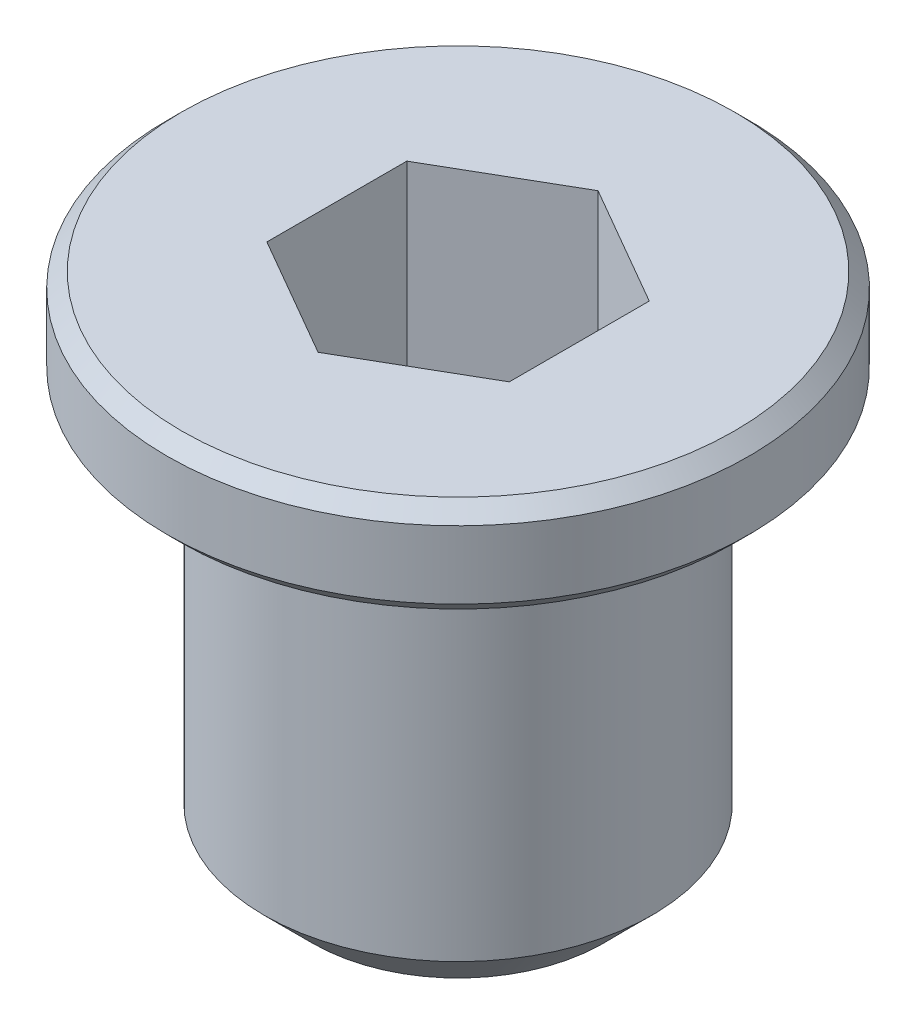
from build123d import *

# Parameters (mm, degrees)
ESQUISSE2_R             = 4
EXTRUSION1_DEPTH        = 8.5
ESQUISSE3_R             = 6
EXTRUSION2_DEPTH        = 2
ESQUISSE4_R             = 2
ENL_V_MAT_EXTRU_1_DEPTH = 11.5
ENL_V_MAT_EXTRU_2_DEPTH = 5.5
CHANFREIN1_SIZE         = 0.3
CHANFREIN2_SIZE         = 1


with BuildPart() as part:
    # Esquisse2 → Extrusion1 (new body)
    with BuildSketch(Plane(origin=(0, 0, 0), x_dir=(1, 0, 0), z_dir=(0, 1, 0))):
        with Locations(Location((0, 0, 0), (0, 0, 270))):  # turned: the seam where the file's is
            Circle(ESQUISSE2_R)
    extrude(amount=-EXTRUSION1_DEPTH)

    # Esquisse3 → Extrusion2 (add)
    with BuildSketch(Plane(origin=(0, 0, 0), x_dir=(-1, 0, 0), z_dir=(0, 1, 0))):
        with Locations(Location((0, 0, 0), (0, 0, 90))):  # turned: the seam where the file's is
            Circle(ESQUISSE3_R)
    extrude(amount=EXTRUSION2_DEPTH)

    # Esquisse4 → Enlèv. mat.-Extru.1 (cut, through all)
    with BuildSketch(Plane(origin=(0, 2, 0), x_dir=(-1, 0, 0), z_dir=(0, 1, 0))):
        with Locations(Location((0, 0, 0), (0, 0, 90))):  # turned: the seam where the file's is
            Circle(ESQUISSE4_R)
    extrude(amount=-ENL_V_MAT_EXTRU_1_DEPTH, mode=Mode.SUBTRACT)

    # Esquisse5 → Enlèv. mat.-Extru.2 (cut)
    with BuildSketch(Plane(origin=(0, 2, 0), x_dir=(-1, 0, 0), z_dir=(0, 1, 0))):
        Polygon((0, -2.886751346), (2.5, -1.443375673), (2.5, 1.443375673), (0, 2.886751346), (-2.5, 1.443375673), (-2.5, -1.443375673), align=None)
    extrude(amount=-ENL_V_MAT_EXTRU_2_DEPTH, mode=Mode.SUBTRACT)

    # Chanfrein1
    chanfrein1_edges = [part.edges().sort_by_distance(p)[0] for p in [
        (0, 0, -6),
        (0, 2, -6),
    ]]
    chamfer(chanfrein1_edges, length=CHANFREIN1_SIZE)

    # Chanfrein2
    chanfrein2_edges = [part.edges().sort_by_distance(p)[0] for p in [
        (0, -8.5, -4),
    ]]
    chamfer(chanfrein2_edges, length=CHANFREIN2_SIZE)


solid = part.part
